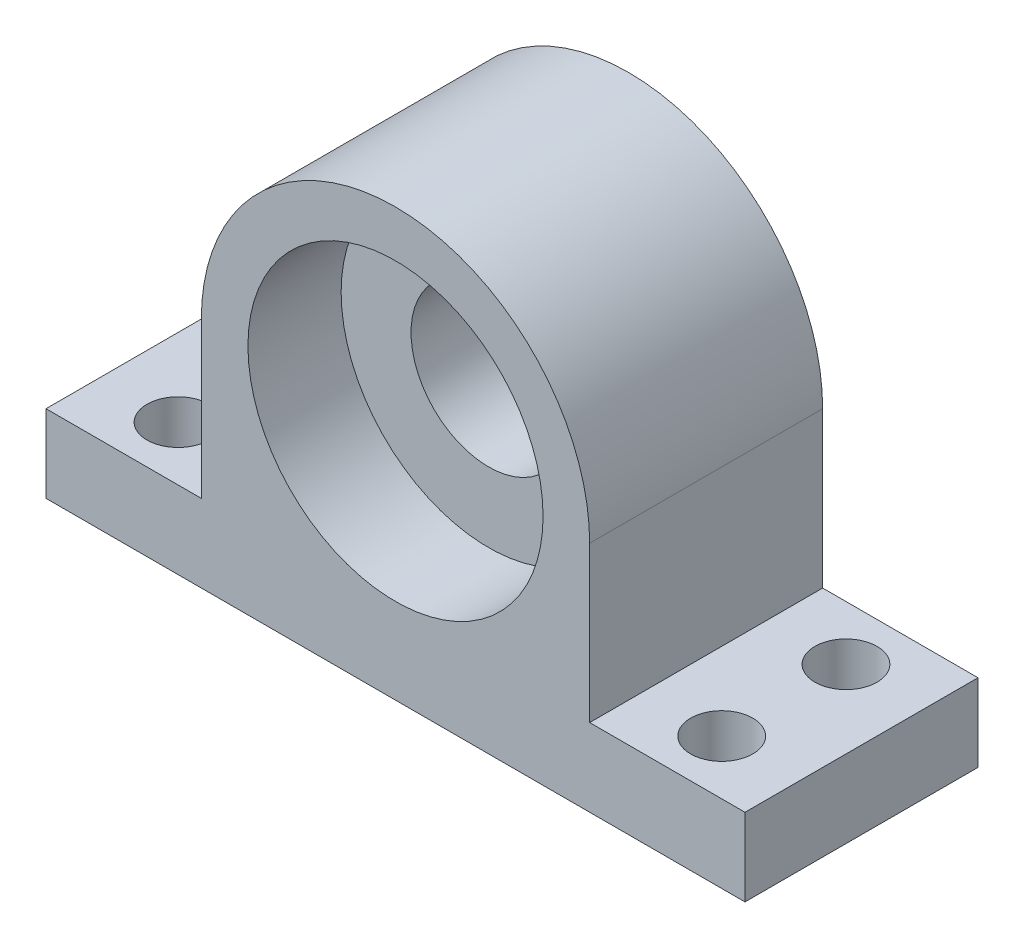
from build123d import *

# Parameters (mm, degrees)
SKETCH1_R           = 5
BOSS_EXTRUDE1_DEPTH = 15
SKETCH2_R           = 9.5
CUT_EXTRUDE1_DEPTH  = 6
SKETCH3_R           = 2
CUT_EXTRUDE2_DEPTH  = 6


with BuildPart() as part:
    # Sketch1 → Boss-Extrude1 (new body)
    with BuildSketch(Plane.XY):
        with BuildLine():
            Line((-12.5, 0), (-12.5, -10))
            Line((-12.5, -10), (-22.5, -10))
            Line((-22.5, -10), (-22.5, -15))
            Line((-22.5, -15), (22.5, -15))
            Line((22.5, -15), (22.5, -10))
            Line((22.5, -10), (12.5, -10))
            Line((12.5, -10), (12.5, 0))
            ThreePointArc((12.5, 0), (0, 12.5), (-12.5, 0))
        make_face()
        Circle(SKETCH1_R, mode=Mode.SUBTRACT)
    extrude(amount=BOSS_EXTRUDE1_DEPTH)

    # Sketch2 → Cut-Extrude1 (cut)
    with BuildSketch(Plane.XY.offset(15)):
        Circle(SKETCH2_R)
    extrude(amount=-CUT_EXTRUDE1_DEPTH, mode=Mode.SUBTRACT)

    # Sketch3 → Cut-Extrude2 (cut)
    with BuildSketch(Plane(origin=(0, -10, 0), x_dir=(1, 0, 0), z_dir=(0, 1, 0))):
        with Locations((17.5, -3.5)):
            Circle(SKETCH3_R)
        with Locations((17.5, -11.5)):
            Circle(SKETCH3_R)
        with Locations((-17.5, -11.5)):
            Circle(SKETCH3_R)
        with Locations((-17.5, -3.5)):
            Circle(SKETCH3_R)
    extrude(amount=-CUT_EXTRUDE2_DEPTH, mode=Mode.SUBTRACT)


solid = part.part
